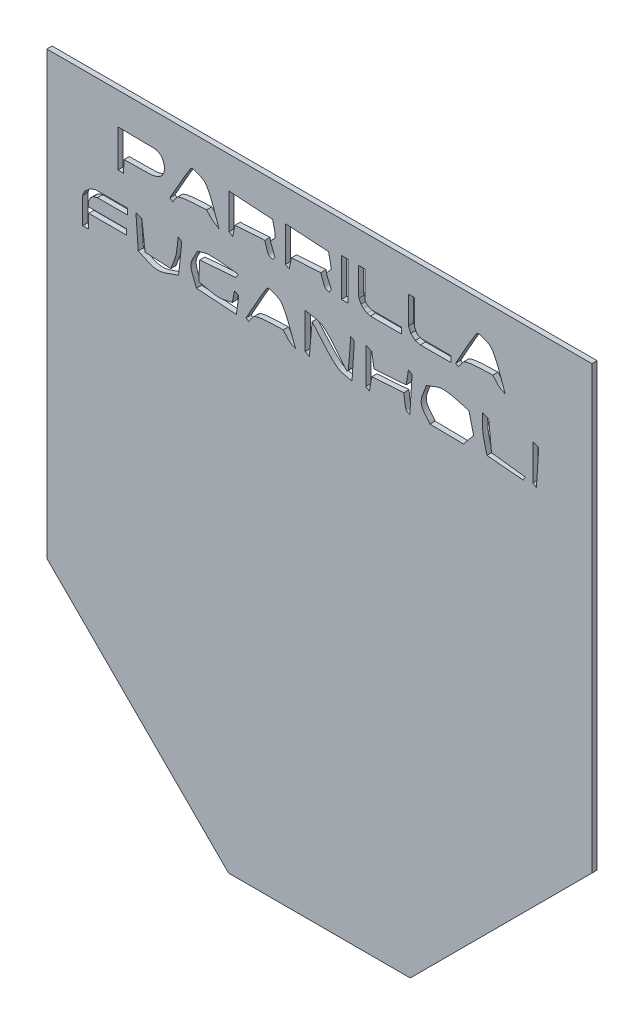
from build123d import *

# Parameters (mm, degrees)
SKETCH1_W           = 210
SKETCH1_H           = 300
BOSS_EXTRUDE1_DEPTH = 2
CUT_EXTRUDE1_DEPTH  = 2
SKETCH4_R           = 5
CUT_EXTRUDE2_DEPTH  = 0.1
SKETCH5_W           = 210
SKETCH5_H           = 60
CUT_EXTRUDE3_DEPTH  = 2
SKETCH7_W           = 2.474747475
SKETCH7_H           = 14.671717172
CUT_EXTRUDE4_DEPTH  = 2


with BuildPart() as part:
    # Sketch1 → Boss-Extrude1 (new body)
    with BuildSketch(Plane.XY):
        with Locations((-62.592592593, -34.722222222)):
            Rectangle(SKETCH1_W, SKETCH1_H)
    extrude(amount=-BOSS_EXTRUDE1_DEPTH)

    # Sketch3 → Cut-Extrude1 (cut)
    with BuildSketch(Plane.XY):
        Polygon((-97.592592593, -184.722222222), (-167.592592593, -114.722222222), (-167.592592593, -184.722222222), align=None)
        Polygon((42.407407407, -184.722222222), (42.407407407, -114.722222222), (-27.592592593, -184.722222222), align=None)
    extrude(amount=-CUT_EXTRUDE1_DEPTH, mode=Mode.SUBTRACT)

    # Sketch4 → Cut-Extrude2 (cut)
    with BuildSketch(Plane(origin=(0, 0, -2), x_dir=(-1, 0, 0), z_dir=(0, 0, -1))):
        with Locations((-32.407407407, -114.722222222)):
            Circle(SKETCH4_R)
        with Locations((-32.407407407, 35.277777778)):
            Circle(SKETCH4_R)
        with Locations((-32.407407407, -14.722222222)):
            Circle(SKETCH4_R)
        with Locations((-32.407407407, -64.722222222)):
            Circle(SKETCH4_R)
        with Locations((157.592592593, -114.722222222)):
            Circle(SKETCH4_R)
        with Locations((157.592592593, 35.277777778)):
            Circle(SKETCH4_R)
        with Locations((157.592592593, -14.722222222)):
            Circle(SKETCH4_R)
        with Locations((157.592592593, -64.722222222)):
            Circle(SKETCH4_R)
        with Locations((97.592592593, -174.722222222)):
            Circle(SKETCH4_R)
        with Locations((27.592592593, -174.722222222)):
            Circle(SKETCH4_R)
        with Locations((-2.457659939, -144.772474754)):
            Circle(SKETCH4_R)
        with Locations((127.642845124, -144.772474754)):
            Circle(SKETCH4_R)
    extrude(amount=-CUT_EXTRUDE2_DEPTH, mode=Mode.SUBTRACT)

    # Sketch5 → Cut-Extrude3 (cut)
    with BuildSketch(Plane(origin=(0, 0, -2), x_dir=(-1, 0, 0), z_dir=(0, 0, -1))):
        with Locations((62.592592593, 85.277777778)):
            Rectangle(SKETCH5_W, SKETCH5_H)
    extrude(amount=-CUT_EXTRUDE3_DEPTH, mode=Mode.SUBTRACT)

    # Sketch7 → Cut-Extrude4 (cut)
    with BuildSketch(Plane.XY):
        with BuildLine():
            Line((-138.062281469, 28.477588743), (-137.885513793, 33.250316016))
            add(Edge.make_bspline(
                [(-140.183493591, 42.972538238), (-135.2929212, 42.913615679), (-130.401318024, 42.912188219), (-125.511776419, 42.795770562), (-125.428470946, 42.793787098), (-125.409540539, 42.656268783), (-125.335008742, 42.619002885), (-124.379059897, 42.141028462), (-123.820424812, 42.114803758), (-123.213796621, 41.204861471), (-121.851970465, 39.162122237), (-121.885065233, 35.895688699), (-124.097635005, 34.487689753), (-125.090692354, 33.855744167), (-126.455013195, 33.463895422), (-127.63298854, 33.427083693), (-131.049337141, 33.320322799), (-134.468005375, 33.309238575), (-137.885513793, 33.250316016)],
                knots=[0, 0, 0, 0, 1, 1, 1, 2, 2, 2, 3, 3, 3, 4, 4, 4, 5, 5, 5, 6, 6, 6, 6], degree=3))
            Line((-140.183493591, 42.972538238), (-140.183493591, 28.65435642))
            Line((-140.183493591, 28.65435642), (-138.062281469, 28.477588743))
        make_face()
        with BuildLine():
            Line((-120.208746116, 29.361427127), (-119.148140055, 28.477588743))
            add(Edge.make_bspline(
                [(-106.067331974, 32.366477632), (-109.60268551, 32.012942279), (-113.267726009, 32.318367039), (-116.67339258, 31.305871572), (-117.874161413, 30.948886243), (-118.32322423, 29.420349686), (-119.148140055, 28.477588743)],
                knots=[0, 0, 0, 0, 1, 1, 1, 2, 2, 2, 2], degree=3))
            add(Edge.make_bspline(
                [(-101.294604702, 28.477588743), (-102.060597968, 28.948969215), (-102.895327434, 29.323594771), (-103.5925845, 29.891730158), (-104.496979175, 30.628644337), (-105.242416149, 31.541561807), (-106.067331974, 32.366477632)],
                knots=[0, 0, 0, 0, 1, 1, 1, 2, 2, 2, 2], degree=3))
            add(Edge.make_bspline(
                [(-120.208746116, 29.361427127), (-117.557230964, 33.898464164), (-115.143466907, 38.583076058), (-112.254200661, 42.972538238), (-112.018352386, 43.330846196), (-111.417500325, 43.479272245), (-111.016826924, 43.326073592), (-109.316913652, 42.676106753), (-107.241034251, 42.197149465), (-106.244099651, 40.67455844), (-103.840604464, 37.003765792), (-102.944436351, 32.543245309), (-101.294604702, 28.477588743)],
                knots=[0, 0, 0, 0, 1, 1, 1, 2, 2, 2, 3, 3, 3, 4, 4, 4, 4], degree=3))
        make_face()
        with BuildLine():
            Line((-80.61278652, 41.911932178), (-97.405715813, 42.972538238))
            Line((-97.405715813, 42.972538238), (-97.405715813, 29.361427127))
            Line((-97.405715813, 29.361427127), (-95.991574399, 28.477588743))
            Line((-95.991574399, 28.477588743), (-95.107736015, 32.720012986))
            Line((-95.107736015, 32.720012986), (-83.617837025, 33.427083693))
            add(Edge.make_bspline(
                [(-80.61278652, 28.477588743), (-81.14308955, 28.772201538), (-81.888860186, 28.842874663), (-82.203695611, 29.361427127), (-82.948355577, 30.587925896), (-83.146456553, 32.071864838), (-83.617837025, 33.427083693)],
                knots=[0, 0, 0, 0, 1, 1, 1, 2, 2, 2, 2], degree=3))
            Line((-80.61278652, 28.477588743), (-79.728948136, 29.714962481))
            Line((-79.728948136, 29.714962481), (-81.496624904, 34.310922077))
            add(Edge.make_bspline(
                [(-80.61278652, 41.911932178), (-80.318173725, 40.085332851), (-79.515247769, 38.269957354), (-79.728948136, 36.432134198), (-79.835255102, 35.51789429), (-80.907399314, 35.017992784), (-81.496624904, 34.310922077)],
                knots=[0, 0, 0, 0, 1, 1, 1, 2, 2, 2, 2], degree=3))
        make_face()
        with BuildLine():
            Line((-59.047129954, 41.911932178), (-75.66329157, 42.972538238))
            Line((-75.66329157, 42.972538238), (-75.66329157, 29.361427127))
            Line((-75.66329157, 29.361427127), (-74.249150156, 28.477588743))
            Line((-74.249150156, 28.477588743), (-73.365311772, 32.720012986))
            Line((-73.365311772, 32.720012986), (-62.052180459, 33.427083693))
            add(Edge.make_bspline(
                [(-58.870362277, 28.477588743), (-59.400665308, 28.772201538), (-60.133223548, 28.851130517), (-60.461271368, 29.361427127), (-61.248224996, 30.585577215), (-61.521877429, 32.071864838), (-62.052180459, 33.427083693)],
                knots=[0, 0, 0, 0, 1, 1, 1, 2, 2, 2, 2], degree=3))
            Line((-58.870362277, 28.477588743), (-57.986523894, 29.891730158))
            Line((-57.986523894, 29.891730158), (-59.930968338, 34.310922077))
            Line((-59.930968338, 34.310922077), (-57.986523894, 36.608901875))
            Line((-57.986523894, 36.608901875), (-59.047129954, 41.911932178))
        make_face()
        with Locations((-52.860261268, 35.813447329)):
            Rectangle(SKETCH7_W, SKETCH7_H)
        with BuildLine():
            Line((-10.08248349, 29.18465945), (-9.021877429, 28.477588743))
            add(Edge.make_bspline(
                [(4.235698329, 32.366477632), (0.700344793, 32.071864838), (-2.966187844, 32.481197082), (-6.370362277, 31.482639248), (-7.652218629, 31.106628052), (-8.138039045, 29.479272245), (-9.021877429, 28.477588743)],
                knots=[0, 0, 0, 0, 1, 1, 1, 2, 2, 2, 2], degree=3))
            add(Edge.make_bspline(
                [(9.008425601, 28.477588743), (8.242432335, 28.890046656), (7.384885633, 29.165418916), (6.710445803, 29.714962481), (5.773194591, 30.478648654), (5.060614154, 31.482639248), (4.235698329, 32.366477632)],
                knots=[0, 0, 0, 0, 1, 1, 1, 2, 2, 2, 2], degree=3))
            add(Edge.make_bspline(
                [(-10.08248349, 29.18465945), (-7.430968338, 33.780619046), (-5.05839186, 38.549211709), (-2.127938035, 42.972538238), (-1.859585508, 43.377598656), (-1.171984184, 43.487786849), (-0.713796621, 43.326073592), (0.926971022, 42.74697913), (2.929036081, 42.307010828), (3.882162975, 40.851326117), (6.327767645, 37.116220804), (7.299671393, 32.602167868), (9.008425601, 28.477588743)],
                knots=[0, 0, 0, 0, 1, 1, 1, 2, 2, 2, 3, 3, 3, 4, 4, 4, 4], degree=3))
        make_face()
        with BuildLine():
            add(Edge.make_bspline(
                [(1.937718531, 4.437184703), (1.4074155, 6.853009619), (0.637673089, 9.228477522), (0.34680944, 11.68465945), (0.104285541, 13.73263904), (0.34680944, 15.809238575), (0.34680944, 17.871528137)],
                knots=[0, 0, 0, 0, 1, 1, 1, 2, 2, 2, 2], degree=3))
            Line((0.34680944, 17.871528137), (2.644789238, 16.987689753))
            Line((2.644789238, 16.987689753), (3.705395298, 6.204861471))
            Line((3.705395298, 6.204861471), (16.786203379, 4.61395238))
            Line((16.786203379, 4.61395238), (15.902364995, 3.199810966))
            Line((15.902364995, 3.199810966), (1.937718531, 4.437184703))
        make_face()
        Polygon((19.614486207, 4.083649349), (19.614486207, 17.871528137), (21.912466005, 16.987689753), (21.028627622, 3.199810966), align=None)
        with BuildLine():
            add(Edge.make_bspline(
                [(-27.759251166, 3.199810966), (-28.230631638, 3.49442376), (-28.979844634, 3.562558724), (-29.17339258, 4.083649349), (-29.797363617, 5.763571371), (-29.76261817, 7.619002885), (-30.057230964, 9.386679652)],
                knots=[0, 0, 0, 0, 1, 1, 1, 2, 2, 2, 2], degree=3))
            Line((-30.057230964, 9.386679652), (-42.430968338, 8.502841269))
            Line((-42.430968338, 8.502841269), (-43.314806722, 3.199810966))
            Line((-43.314806722, 3.199810966), (-44.728948136, 4.083649349))
            Line((-44.728948136, 4.083649349), (-44.728948136, 17.871528137))
            Line((-44.728948136, 17.871528137), (-42.430968338, 16.987689753))
            Line((-42.430968338, 16.987689753), (-41.547129954, 11.507891774))
            Line((-41.547129954, 11.507891774), (-29.17339258, 12.391730158))
            Line((-29.17339258, 12.391730158), (-28.289554197, 17.871528137))
            Line((-28.289554197, 17.871528137), (-26.875412782, 16.987689753))
            Line((-26.875412782, 16.987689753), (-27.759251166, 3.199810966))
        make_face()
        with BuildLine():
            add(Edge.make_bspline(
                [(-50.031978439, 3.199810966), (-51.976422883, 3.847959114), (-54.259435805, 3.870629643), (-55.865311772, 5.14425541), (-59.523778718, 8.04579816), (-62.228948136, 11.979272245), (-65.410766318, 15.396780663)],
                knots=[0, 0, 0, 0, 1, 1, 1, 2, 2, 2, 2], degree=3))
            Line((-65.410766318, 15.396780663), (-66.471372378, 3.199810966))
            Line((-66.471372378, 3.199810966), (-68.062281469, 4.083649349))
            Line((-68.062281469, 4.083649349), (-68.062281469, 17.871528137))
            add(Edge.make_bspline(
                [(-68.062281469, 17.871528137), (-65.764301671, 17.223379989), (-63.060839896, 17.382851247), (-61.168342075, 15.927083693), (-57.495361229, 13.101713811), (-55.040395947, 8.97422174), (-51.976422883, 5.497790764)],
                knots=[0, 0, 0, 0, 1, 1, 1, 2, 2, 2, 2], degree=3))
            add(Edge.make_bspline(
                [(-51.976422883, 5.497790764), (-51.799655207, 5.792403558), (-51.485131579, 6.04027655), (-51.446119853, 6.381629147), (-51.009955504, 10.198067205), (-50.856894264, 14.041561807), (-50.562281469, 17.871528137)],
                knots=[0, 0, 0, 0, 1, 1, 1, 2, 2, 2, 2], degree=3))
            Line((-50.562281469, 17.871528137), (-49.148140055, 16.987689753))
            Line((-49.148140055, 16.987689753), (-50.031978439, 3.199810966))
        make_face()
        with BuildLine():
            add(Edge.make_bspline(
                [(-116.850160257, 5.14425541), (-119.619520527, 4.378262144), (-122.285639514, 2.780989213), (-125.158241065, 2.846275612), (-127.730003887, 2.904724767), (-129.989890897, 4.61395238), (-132.405715813, 5.497790764)],
                knots=[0, 0, 0, 0, 1, 1, 1, 2, 2, 2, 2], degree=3))
            Line((-132.405715813, 5.497790764), (-133.289554197, 17.871528137))
            Line((-133.289554197, 17.871528137), (-130.991574399, 16.987689753))
            Line((-130.991574399, 16.987689753), (-129.754200661, 6.381629147))
            Line((-129.754200661, 6.381629147), (-119.855210762, 5.851326117))
            add(Edge.make_bspline(
                [(-119.855210762, 5.851326117), (-119.207062614, 7.619002885), (-118.341991925, 9.321647591), (-117.910766318, 11.15435642), (-117.393513853, 13.352679396), (-117.321540729, 15.632470898), (-117.026927934, 17.871528137)],
                knots=[0, 0, 0, 0, 1, 1, 1, 2, 2, 2, 2], degree=3))
            Line((-117.026927934, 17.871528137), (-115.61278652, 16.987689753))
            Line((-115.61278652, 16.987689753), (-116.850160257, 5.14425541))
        make_face()
        with BuildLine():
            add(Edge.make_bspline(
                [(-109.956220863, 4.260417026), (-110.66329157, 6.499474265), (-112.143548937, 8.630472431), (-112.077432984, 10.977588743), (-112.017958242, 13.088942118), (-110.427601335, 14.866477632), (-109.60268551, 16.810922077)],
                knots=[0, 0, 0, 0, 1, 1, 1, 2, 2, 2, 2], degree=3))
            add(Edge.make_bspline(
                [(-109.60268551, 16.810922077), (-108.129621537, 17.16445743), (-106.698292266, 17.854507927), (-105.183493591, 17.871528137), (-101.401197758, 17.914025843), (-97.641406048, 17.282302548), (-93.870362277, 16.987689753)],
                knots=[0, 0, 0, 0, 1, 1, 1, 2, 2, 2, 2], degree=3))
            Line((-93.870362277, 16.987689753), (-94.754200661, 15.396780663))
            Line((-94.754200661, 15.396780663), (-108.718847126, 14.336174602))
            Line((-108.718847126, 14.336174602), (-109.072382479, 6.911932178))
            add(Edge.make_bspline(
                [(-109.072382479, 6.911932178), (-106.538712446, 6.440551706), (-104.046345261, 5.603611567), (-101.471372378, 5.497790764), (-99.680824076, 5.424206587), (-97.936018843, 6.087016353), (-96.168342075, 6.381629147)],
                knots=[0, 0, 0, 0, 1, 1, 1, 2, 2, 2, 2], degree=3))
            Line((-96.168342075, 6.381629147), (-95.284503692, 10.800821067))
            Line((-95.284503692, 10.800821067), (-93.693594601, 9.916982683))
            Line((-93.693594601, 9.916982683), (-94.577432984, 3.199810966))
            Line((-94.577432984, 3.199810966), (-109.956220863, 4.260417026))
        make_face()
        with BuildLine():
            Line((-90.865311772, 3.906881673), (-89.804705712, 3.199810966))
            add(Edge.make_bspline(
                [(-76.547129954, 7.088699854), (-80.08248349, 6.79408706), (-83.749016127, 7.203419304), (-87.15319056, 6.204861471), (-88.435046912, 5.828850274), (-88.920867328, 4.201494467), (-89.804705712, 3.199810966)],
                knots=[0, 0, 0, 0, 1, 1, 1, 2, 2, 2, 2], degree=3))
            add(Edge.make_bspline(
                [(-71.774402681, 3.199810966), (-72.540395947, 3.612268878), (-73.39794265, 3.887641138), (-74.072382479, 4.437184703), (-75.009633692, 5.200870876), (-75.722214129, 6.204861471), (-76.547129954, 7.088699854)],
                knots=[0, 0, 0, 0, 1, 1, 1, 2, 2, 2, 2], degree=3))
            add(Edge.make_bspline(
                [(-90.865311772, 3.906881673), (-88.213796621, 8.502841269), (-85.802461215, 13.24599908), (-82.910766318, 17.694760461), (-82.676986641, 18.054421501), (-82.076528908, 18.194890842), (-81.67339258, 18.048295814), (-80.038187441, 17.453675763), (-78.042590421, 17.021284494), (-77.077432984, 15.573548339), (-74.588266667, 11.839798863), (-73.542079449, 7.32439009), (-71.774402681, 3.199810966)],
                knots=[0, 0, 0, 0, 1, 1, 1, 2, 2, 2, 3, 3, 3, 4, 4, 4, 4], degree=3))
        make_face()
        Polygon((-153.076405557, 15.116147355), (-153.613429305, 13.903499639), (-153.794604702, 13.275568541), (-153.794604702, 3.199810966), (-151.496624904, 3.199810966), (-151.496624904, 8.502841269), (-137.001675409, 8.502841269), (-137.001675409, 10.62405339), (-151.496624904, 10.62405339), (-151.496624904, 12.568497834), (-150.905416375, 13.903499639), (-149.733841737, 14.913477775), (-148.138039045, 15.396780663), (-136.471372378, 15.396780663), (-136.471372378, 17.694760461), (-148.845109752, 17.694760461), (-150.905416375, 16.987689753), (-151.9306689, 16.10385137), align=None)
        with BuildLine():
            Line((-3.188544096, 8.502841269), (-4.956220863, 15.927083693))
            add(Edge.make_bspline(
                [(-21.395614803, 16.10385137), (-19.215480123, 16.751999518), (-17.129520592, 18.072750758), (-14.855210762, 18.048295814), (-11.480835209, 18.012012206), (-8.255884163, 16.6341544), (-4.956220863, 15.927083693)],
                knots=[0, 0, 0, 0, 1, 1, 1, 2, 2, 2, 2], degree=3))
            add(Edge.make_bspline(
                [(-19.981473389, 3.906881673), (-21.101002008, 5.67455844), (-23.099079541, 7.131462009), (-23.340059247, 9.209911976), (-23.615044563, 11.581660329), (-22.043762951, 13.805871572), (-21.395614803, 16.10385137)],
                knots=[0, 0, 0, 0, 1, 1, 1, 2, 2, 2, 2], degree=3))
            Line((-19.981473389, 3.906881673), (-7.077432984, 3.730113996))
            Line((-7.077432984, 3.730113996), (-3.188544096, 8.502841269))
        make_face()
        Polygon((-27.408608597, 30.461884863), (-28.289554197, 32.543245309), (-28.289554197, 43.149305915), (-25.991574399, 43.149305915), (-25.991574399, 33.427083693), (-25.256923504, 31.887167489), (-24.521448127, 31.156223063), (-23.16329157, 30.775568541), (-11.850160257, 30.775568541), (-11.850160257, 28.477588743), (-23.693594601, 28.477588743), (-25.624248951, 29.0186989), align=None)
        Polygon((-47.380463288, 43.149305915), (-45.08248349, 43.149305915), (-45.08248349, 33.073548339), (-44.51032291, 31.887167489), (-43.314806722, 31.072827712), (-42.254200661, 30.775568541), (-30.941069348, 30.775568541), (-30.941069348, 28.477588743), (-42.961271368, 28.477588743), (-44.195289592, 28.82345065), (-45.585142465, 29.626578642), (-46.604367904, 30.63952507), (-47.01205808, 31.584625023), (-47.380463288, 32.189709955), (-47.557230964, 33.427083693), (-47.557230964, 42.972538238), align=None)
    extrude(amount=-CUT_EXTRUDE4_DEPTH, mode=Mode.SUBTRACT)


solid = part.part
